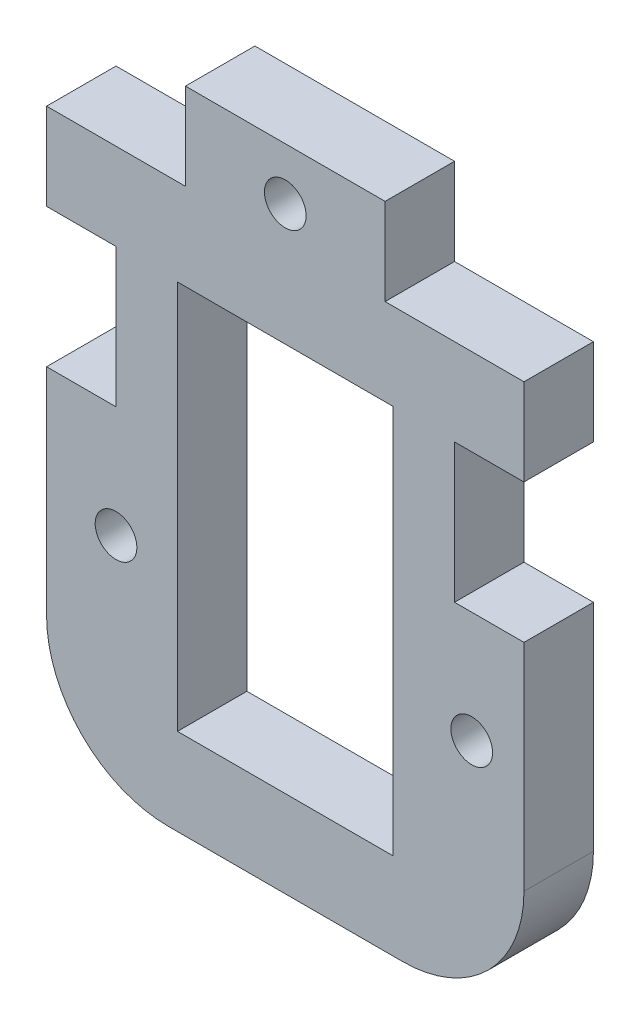
from build123d import *

# Parameters (mm, degrees)
SKETCH1_R           = 1.2
SKETCH1_W           = 12.42
SKETCH1_H           = 22.42
BOSS_EXTRUDE1_DEPTH = 4
FILLET1_R           = 7


with BuildPart() as part:
    # Sketch1 → Boss-Extrude1 (new body)
    with BuildSketch(Plane.XY):
        Polygon((8, 37.42), (8, 32.42), (0, 32.42), (0, 27.42), (4, 27.42), (4, 19.42), (0, 19.42), (0, 0), (27.5, 0), (27.5, 19.42), (23.5, 19.42), (23.5, 27.42), (27.5, 27.42), (27.5, 32.42), (19.5, 32.42), (19.5, 37.42), align=None)
        with Locations((4, 13)):
            Circle(SKETCH1_R, mode=Mode.SUBTRACT)
        with Locations((13.75, 16.21)):
            Rectangle(SKETCH1_W, SKETCH1_H, mode=Mode.SUBTRACT)
        with Locations((24.49, 13.01)):
            Circle(SKETCH1_R, mode=Mode.SUBTRACT)
        with Locations((13.75, 34.42)):
            Circle(SKETCH1_R, mode=Mode.SUBTRACT)
    extrude(amount=BOSS_EXTRUDE1_DEPTH)

    # Fillet1
    fillet1_edges = [part.edges().sort_by_distance(p)[0] for p in [
        (27.5, 0, 2),
        (0, 0, 2),
    ]]
    fillet(fillet1_edges, radius=FILLET1_R)


solid = part.part
